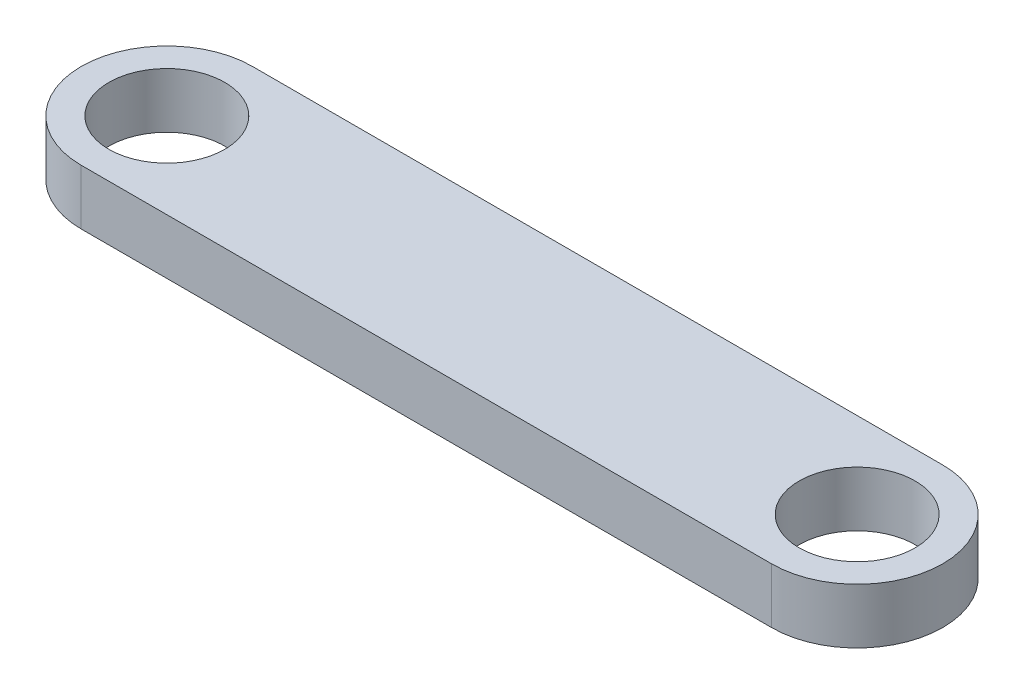
from build123d import *

# Parameters (mm, degrees)
SKETCH1_R           = 2.1
BOSS_EXTRUDE1_DEPTH = 2


with BuildPart() as part:
    # Sketch1 → Boss-Extrude1 (new body)
    with BuildSketch(Plane(origin=(0, 0, 0), x_dir=(1, 0, 0), z_dir=(0, 1, 0))):
        with BuildLine():
            Line((-12.5, 3.1), (12.5, 3.1))
            ThreePointArc((12.5, 3.1), (15.6, 0), (12.5, -3.1))
            Line((12.5, -3.1), (-12.5, -3.1))
            ThreePointArc((-12.5, -3.1), (-15.6, 0), (-12.5, 3.1))
        make_face()
        with Locations((-12.5, 0)):
            Circle(SKETCH1_R, mode=Mode.SUBTRACT)
        with Locations((12.5, 0)):
            Circle(SKETCH1_R, mode=Mode.SUBTRACT)
    extrude(amount=BOSS_EXTRUDE1_DEPTH)


solid = part.part
